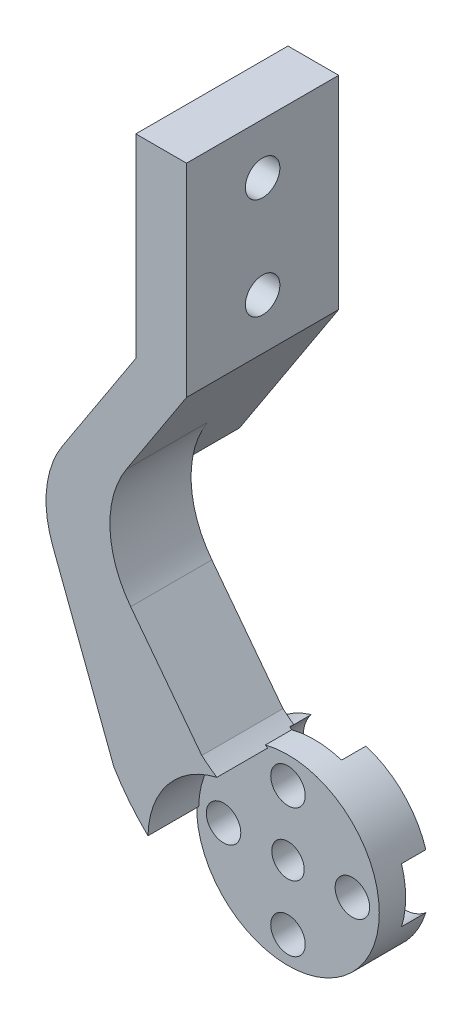
from build123d import *

# Parameters (mm, degrees)
SKETCH_1_R                   = 1.6
EXTRUDE_1_DEPTH              = 8
EXTRUDE_2_DEPTH              = 15
FILLET_1_R                   = 10
SKETCH_3_R                   = 8.8
CUT_EXTRUDE_1_DEPTH          = 5
SKETCH_4_R                   = 9
SKETCH_4_R_2                 = 1.6000000000000003
EXTRUDE_3_DEPTH              = 2
EXTRUDE_3_DIRECTION_2_REACH  = 64.924
HOLE_WIZARD_M3_1_D           = 3.4
HOLE_WIZARD_M3_1_CBORE_D     = 7
HOLE_WIZARD_M3_1_CBORE_DEPTH = 2.4
HOLE_WIZARD_M3_1_2_D         = 3.4


with BuildPart() as part:
    # 스케치1 → 보스-돌출1 (new body)
    with BuildSketch(Plane.XY):
        with BuildLine():
            Line((-12.16427952654043, 4.378638787940105), (-20.000000000000004, 25))
            Line((-20.000000000000004, 25), (-10.000000000000002, 40.33333333333329))
            Line((-10.000000000000002, 40.33333333333329), (-10.000000000000005, 59.5))
            Line((-10.000000000000005, 59.5), (-5.000000000000006, 59.5))
            Line((-5.000000000000006, 59.5), (-5.000000000000006, 39.5))
            Line((-5.000000000000006, 39.5), (-14.782608695652206, 24.5))
            Line((-14.782608695652206, 24.5), (-3.493383141466383, 9.687944683099722))
            ThreePointArc((-3.493383141466383, 9.687944683099722), (-0.9090438204077795, 7.9117774771707445), (1.988107412927463, 6.7117381440773505))
            ThreePointArc((1.988107412927463, 6.7117381440773505), (5.440021730198806, -4.405242737348851), (-6.151719788633741, -3.3401113218172886))
            ThreePointArc((-6.151719788633741, -3.3401113218172886), (-7.393946440543873, -1.418082905068042), (-8.914100921678212, 0.29260427936827865))
            ThreePointArc((-8.914100921678212, 0.29260427936827865), (-10.673096649546496, 2.229107553388852), (-12.16427952654043, 4.378638787940105))
        make_face()
        Circle(SKETCH_1_R, mode=Mode.SUBTRACT)
    extrude(amount=EXTRUDE_1_DEPTH)

    # 스케치2 → 보스-돌출2 (add)
    with BuildSketch(Plane.XY.offset(8)):
        Polygon((-14.782608695652206, 24.5), (-18.671865990081887, 27.036472148541108), (-10.000000000000002, 40.33333333333329), (-10.000000000000005, 59.5), (-5.000000000000006, 59.5), (-5.000000000000006, 39.5), align=None)
    extrude(amount=-EXTRUDE_2_DEPTH)

    # 필렛1
    fillet_1_edges = [part.edges().sort_by_distance(p)[0] for p in [
        (-14.782608695652206, 24.5, 4),
        (-20.000000000000004, 25, 4),
    ]]
    fillet(fillet_1_edges, radius=FILLET_1_R)

    # 스케치3 → 컷-돌출1 (cut)
    with BuildSketch(Plane.XY.offset(8)):
        Circle(SKETCH_3_R)
    extrude(amount=-CUT_EXTRUDE_1_DEPTH, mode=Mode.SUBTRACT)

    # 스케치4 → 보스-돌출3 (add)
    with BuildSketch(Plane(origin=(0, 0, 0), x_dir=(-1, 0, 0), z_dir=(0, 0, -1))):
        Circle(SKETCH_4_R)
        Circle(SKETCH_4_R_2, mode=Mode.SUBTRACT)
    extrude(amount=EXTRUDE_3_DEPTH)

    # 보스-돌출3 direction 2: up to this face of the body (flat: up to its plane)
    extrude_3_direction_2_end = Plane(part.part.faces().sort_by_distance((-0.17036429, 7.291732251, 3))[0])
    # 스케치4 → 보스-돌출3 direction 2 (add, up to the picked face)
    with BuildSketch(Plane(origin=(0, 0, 0), x_dir=(-1, 0, 0), z_dir=(0, 0, -1)), mode=Mode.PRIVATE) as extrude_3_direction_2_sk1:
        Circle(SKETCH_4_R)
        Circle(SKETCH_4_R_2, mode=Mode.SUBTRACT)
    extrude_3_direction_2_tool1 = split(extrude(extrude_3_direction_2_sk1.sketch, amount=-EXTRUDE_3_DIRECTION_2_REACH, mode=Mode.PRIVATE), bisect_by=extrude_3_direction_2_end, keep=Keep.BOTH, mode=Mode.PRIVATE)
    add(extrude_3_direction_2_tool1.solids().sort_by(Axis((8.745442, 0, 0), (0, 0, 1)))[0])

    # Hole Wizard M3 _ _ _ _1 (through all)
    with Locations(Plane(origin=(0, 0, -2), x_dir=(-1, 0, 0), z_dir=(0, 0, -1))):
        with Locations((0, 6.35), (6.35, 0), (0, -6.35), (-6.35, 0)):
            CounterBoreHole(HOLE_WIZARD_M3_1_D / 2, HOLE_WIZARD_M3_1_CBORE_D / 2, HOLE_WIZARD_M3_1_CBORE_DEPTH)

    # Hole Wizard M3 _ _1 2 (through all)
    with Locations(Plane.ZY.offset(9.999999999999995)):
        with Locations((0.5, 54.5), (0.5, 44.5)):
            Hole(HOLE_WIZARD_M3_1_2_D / 2)


solid = part.part
